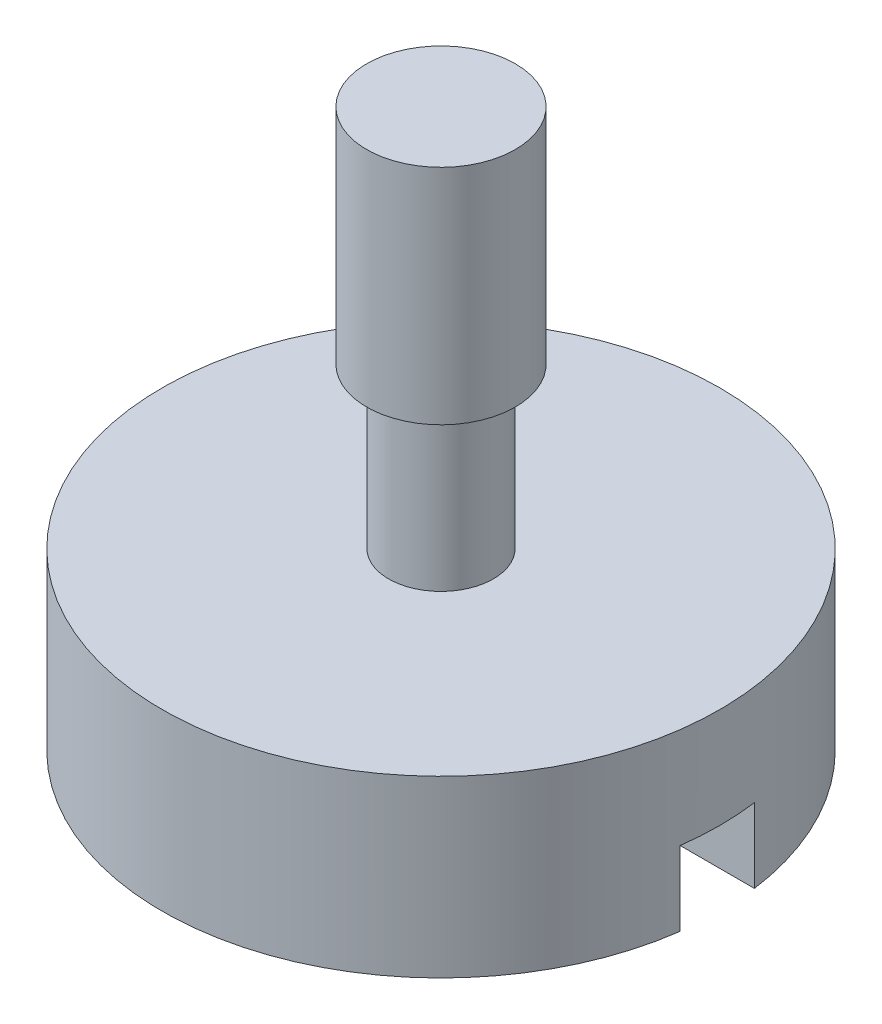
from build123d import *

# Parameters (mm, degrees)
SCHIZZO2_W               = 20.11559051
SCHIZZO2_H               = 2
TAGLIO_ESTRUSIONE1_DEPTH = 2


with BuildPart() as part:
    # Schizzo1 → Rivoluzione1 (revolve)
    with BuildSketch(Plane.XY):
        Polygon((0, 15), (2, 15), (2, 9), (1.409533837, 9), (1.409533837, 4.7), (7.5, 4.7), (7.5, 0), (0, 0), align=None)
    revolve(axis=Axis((0, -3.578292252, 0), (0, 1, 0)))

    # Schizzo2 → Taglio-Estrusione1 (cut)
    with BuildSketch(Plane.XZ):
        Rectangle(SCHIZZO2_W, SCHIZZO2_H)
    extrude(amount=-TAGLIO_ESTRUSIONE1_DEPTH, mode=Mode.SUBTRACT)


solid = part.part
